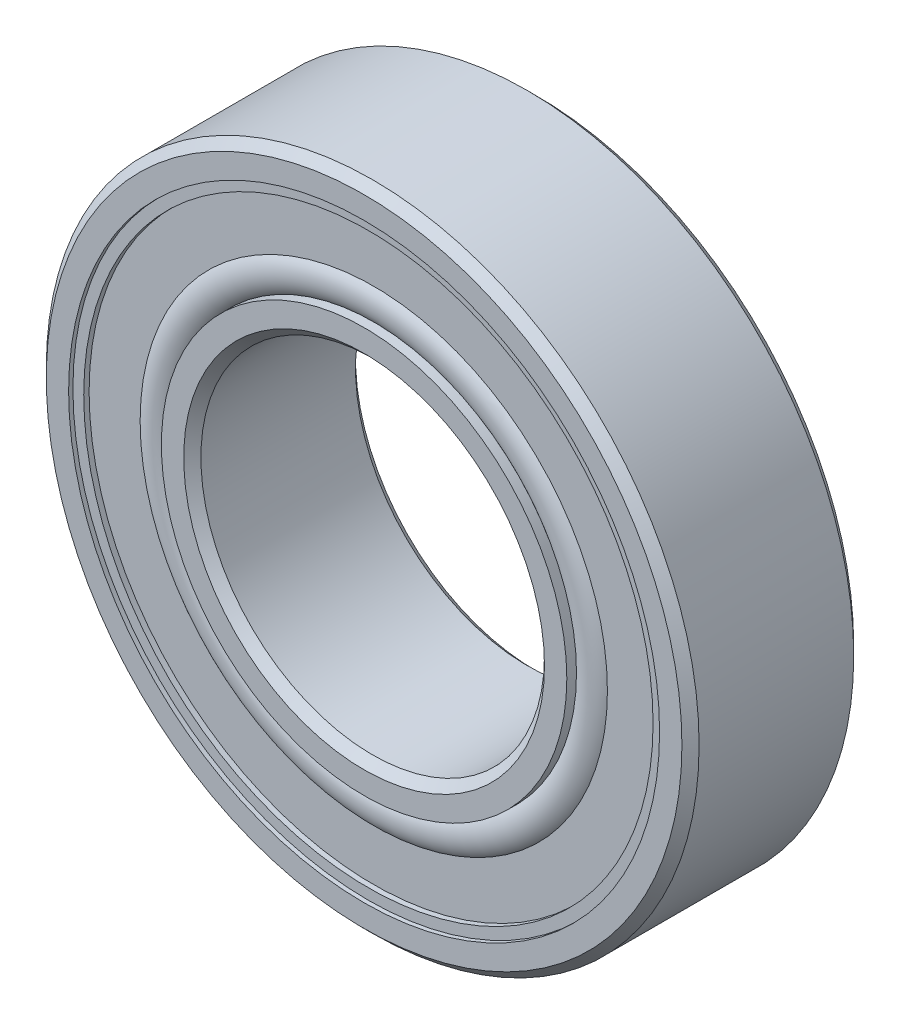
from build123d import *

# Parameters (mm, degrees)
CIRPATTERN1_COUNT = 9


with BuildPart() as part:
    # Sketch3 → Revolve1 (revolve)
    with BuildSketch(Plane(origin=(0, 0, 0), x_dir=(0, 0, -1), z_dir=(1, 0, 0))):
        with BuildLine():
            Line((-2.5, 9.25), (-2.5, 8.6))
            Line((-2.5, 8.6), (-1.111111111, 8.6))
            ThreePointArc((-1.111111111, 8.6), (0, 8.998447283), (1.111111111, 8.6))
            Line((1.111111111, 8.6), (2.5, 8.6))
            Line((2.5, 8.6), (2.5, 9.25))
            Line((2.5, 9.25), (2.25, 9.5))
            Line((2.25, 9.5), (-2.25, 9.5))
            Line((-2.25, 9.5), (-2.5, 9.25))
        make_face()
        with BuildLine():
            Line((-2.5, 5.25), (-2.5, 5.9))
            Line((-2.5, 5.9), (-1.111111111, 5.9))
            ThreePointArc((-1.111111111, 5.9), (0, 5.501552717), (1.111111111, 5.9))
            Line((1.111111111, 5.9), (2.5, 5.9))
            Line((2.5, 5.9), (2.5, 5.25))
            Line((2.5, 5.25), (2.25, 5))
            Line((2.25, 5), (-2.25, 5))
            Line((-2.25, 5), (-2.5, 5.25))
        make_face()
    revolve(axis=Axis((0, 0, 2.5), (0, 0, -1)))


with BuildPart() as body_2:
    # Sketch4 → Revolve2 (revolve)
    with BuildSketch(Plane(origin=(0, 0, 0), x_dir=(0, 0, -1), z_dir=(1, 0, 0))):
        with BuildLine():
            Line((-1.748447283, 7.25), (1.748447283, 7.25))
            ThreePointArc((1.748447283, 7.25), (0, 8.998447283), (-1.748447283, 7.25))
        make_face()
    revolve(axis=Axis((0, 7.25, 1.748447283), (0, 0, -1)))


with BuildPart() as cirpattern1_1:
    # CirPattern1: pattern copy
    add(body_2.part.rotate(Axis((0, 0, 0), (0, 0, 1)), 1 * 360 / CIRPATTERN1_COUNT))


with BuildPart() as cirpattern1_2:
    # CirPattern1: pattern copy
    add(body_2.part.rotate(Axis((0, 0, 0), (0, 0, 1)), 2 * 360 / CIRPATTERN1_COUNT))


with BuildPart() as cirpattern1_3:
    # CirPattern1: pattern copy
    add(body_2.part.rotate(Axis((0, 0, 0), (0, 0, 1)), 3 * 360 / CIRPATTERN1_COUNT))


with BuildPart() as cirpattern1_4:
    # CirPattern1: pattern copy
    add(body_2.part.rotate(Axis((0, 0, 0), (0, 0, 1)), 4 * 360 / CIRPATTERN1_COUNT))


with BuildPart() as cirpattern1_5:
    # CirPattern1: pattern copy
    add(body_2.part.rotate(Axis((0, 0, 0), (0, 0, 1)), 5 * 360 / CIRPATTERN1_COUNT))


with BuildPart() as cirpattern1_6:
    # CirPattern1: pattern copy
    add(body_2.part.rotate(Axis((0, 0, 0), (0, 0, 1)), 6 * 360 / CIRPATTERN1_COUNT))


with BuildPart() as cirpattern1_7:
    # CirPattern1: pattern copy
    add(body_2.part.rotate(Axis((0, 0, 0), (0, 0, 1)), 7 * 360 / CIRPATTERN1_COUNT))


with BuildPart() as cirpattern1_8:
    # CirPattern1: pattern copy
    add(body_2.part.rotate(Axis((0, 0, 0), (0, 0, 1)), 8 * 360 / CIRPATTERN1_COUNT))


with BuildPart() as body_11:
    # Sketch5 → Revolve3 (revolve)
    with BuildSketch(Plane(origin=(0, 0, 0), x_dir=(0, 0, -1), z_dir=(1, 0, 0))):
        with BuildLine():
            Line((-2.375, 8.6), (-1.748447283, 8.6))
            Line((-1.748447283, 8.6), (-1.748447283, 5.9))
            Line((-1.748447283, 5.9), (-2.218361821, 5.9))
            ThreePointArc((-2.218361821, 5.9), (-2.375, 6.35), (-2.218361821, 6.8))
            Line((-2.218361821, 6.8), (-2.218361821, 8.285))
            Line((-2.218361821, 8.285), (-2.375, 8.285))
            Line((-2.375, 8.285), (-2.375, 8.6))
        make_face()
        with BuildLine():
            Line((2.218361821, 5.9), (1.748447283, 5.9))
            Line((1.748447283, 5.9), (1.748447283, 8.6))
            Line((1.748447283, 8.6), (2.375, 8.6))
            Line((2.375, 8.6), (2.375, 8.285))
            Line((2.375, 8.285), (2.218361821, 8.285))
            Line((2.218361821, 8.285), (2.218361821, 6.8))
            ThreePointArc((2.218361821, 6.8), (2.375, 6.35), (2.218361821, 5.9))
        make_face()
    revolve(axis=Axis((0, 0, 2.5), (0, 0, -1)))


solid = Compound([part.part, body_2.part, cirpattern1_1.part, cirpattern1_2.part, cirpattern1_3.part, cirpattern1_4.part, cirpattern1_5.part, cirpattern1_6.part, cirpattern1_7.part, cirpattern1_8.part, body_11.part])
